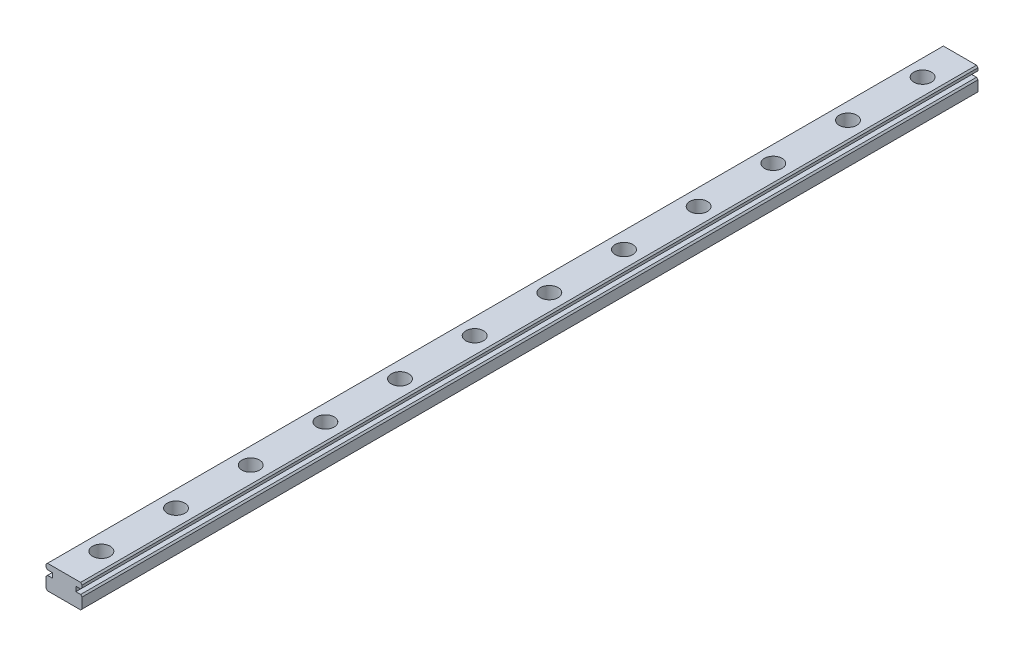
from build123d import *

# Parameters (mm, degrees)
BOSS_EXTRUDE1_DEPTH  = 300
CHAMFER1_SIZE        = 0.5
SKETCH2_R            = 2.95
CUT_EXTRUDE1_DEPTH   = 5.6
LPATTERN1_COUNT      = 6
LPATTERN1_PITCH      = 25
LPATTERN2_COUNT      = 7
LPATTERN2_PITCH      = 25
SKETCH3_R            = 1.6
CUT_EXTRUDE2_DEPTH   = 9
LPATTERN3_COUNT      = 7
LPATTERN3_PITCH      = 25
LPATTERN3_COUNT_DIR2 = 6
LPATTERN3_PITCH_DIR2 = 25


with BuildPart() as part:
    # Sketch1 → Boss-Extrude1 (new body)
    with BuildSketch(Plane.XY):
        Polygon((6.05, 2.1), (3.95, 2.1), (3.95, 0.5), (6.05, 0.5), (6.05, -4), (-6.05, -4), (-6.05, 0.5), (-3.95, 0.5), (-3.95, 2.1), (-6.05, 2.1), (-6.05, 4), (6.05, 4), align=None)
    extrude(amount=BOSS_EXTRUDE1_DEPTH)

    # Chamfer1
    chamfer1_edges = [part.edges().sort_by_distance(p)[0] for p in [
        (6.05, -4, 150),
        (-6.05, -4, 150),
        (-6.05, 0.5, 150),
        (-6.05, 2.1, 150),
        (-6.05, 4, 150),
        (6.05, 4, 150),
        (6.05, 2.1, 150),
        (6.05, 0.5, 150),
    ]]
    chamfer(chamfer1_edges, length=CHAMFER1_SIZE)

    # Sketch2 → Cut-Extrude1 (cut)
    with BuildSketch(Plane(origin=(0, 4, 0), x_dir=(1, 0, 0), z_dir=(0, 1, 0))):
        with Locations((0, -137.5)):
            Circle(SKETCH2_R)
        with Locations((0, -162.5)):
            Circle(SKETCH2_R)
    cut_extrude1 = extrude(amount=-CUT_EXTRUDE1_DEPTH, mode=Mode.SUBTRACT)

    # LPattern1: Cut-Extrude1 ×6
    with Locations(*[(0, 0, i * LPATTERN1_PITCH) for i in range(1, LPATTERN1_COUNT)]):
        add(cut_extrude1, mode=Mode.SUBTRACT)

    # LPattern2: Cut-Extrude1 ×7
    with Locations(*[(0, 0, -i * LPATTERN2_PITCH) for i in range(1, LPATTERN2_COUNT)]):
        add(cut_extrude1, mode=Mode.SUBTRACT)

    # Sketch3 → Cut-Extrude2 (cut, through all)
    with BuildSketch(Plane(origin=(0, 4, 0), x_dir=(1, 0, 0), z_dir=(0, 1, 0))):
        with Locations((0, -162.5)):
            Circle(SKETCH3_R)
        with Locations((0, -137.5)):
            Circle(SKETCH3_R)
    cut_extrude2 = extrude(amount=-CUT_EXTRUDE2_DEPTH, mode=Mode.SUBTRACT)

    # LPattern3: Cut-Extrude2 7 × 6
    with Locations(*[Vector(0, 0, -1) * (i * LPATTERN3_PITCH) + Vector(0, 0, 1) * (j * LPATTERN3_PITCH_DIR2) for i in range(LPATTERN3_COUNT) for j in range(LPATTERN3_COUNT_DIR2) if (i, j) != (0, 0)]):
        add(cut_extrude2, mode=Mode.SUBTRACT)


solid = part.part
